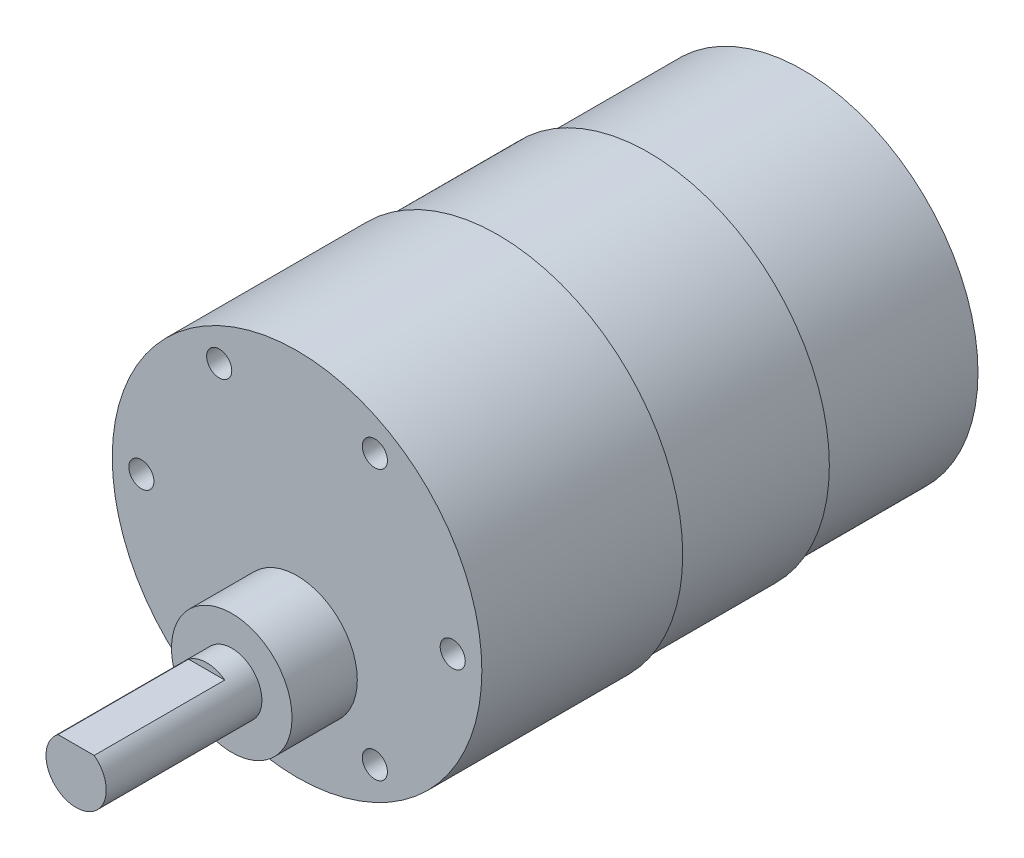
from build123d import *

# Parameters (mm, degrees)
SKETCH1_R                       = 17.4
BOSS_EXTRUDE1_DEPTH             = 15.4
SKETCH2_R                       = 18
BOSS_EXTRUDE2_DEPTH             = 15
SKETCH3_R                       = 18.4
BOSS_EXTRUDE3_DEPTH             = 20
SKETCH4_R                       = 6
BOSS_EXTRUDE4_DEPTH             = 6.5
SKETCH5_R                       = 3
BOSS_EXTRUDE5_DEPTH             = 15.5
CUT_EXTRUDE1_DEPTH              = 13
TAP_DRILL_FOR_M3X0_5_TAP1_D     = 2.5
TAP_DRILL_FOR_M3X0_5_TAP1_DEPTH = 10.76


with BuildPart() as part:
    # Sketch1 → Boss-Extrude1 (new body)
    with BuildSketch(Plane.XY):
        Circle(SKETCH1_R)
    extrude(amount=BOSS_EXTRUDE1_DEPTH)

    # Sketch2 → Boss-Extrude2 (add)
    with BuildSketch(Plane.XY.offset(15.4)):
        Circle(SKETCH2_R)
    extrude(amount=BOSS_EXTRUDE2_DEPTH)

    # Sketch3 → Boss-Extrude3 (add)
    with BuildSketch(Plane.XY.offset(30.4)):
        Circle(SKETCH3_R)
    extrude(amount=BOSS_EXTRUDE3_DEPTH)

    # Sketch4 → Boss-Extrude4 (add)
    with BuildSketch(Plane.XY.offset(50.4)):
        with Locations((0, -7)):
            Circle(SKETCH4_R)
    extrude(amount=BOSS_EXTRUDE4_DEPTH)

    # Sketch5 → Boss-Extrude5 (add)
    with BuildSketch(Plane.XY.offset(56.9)):
        with Locations((0, -7)):
            Circle(SKETCH5_R)
    extrude(amount=BOSS_EXTRUDE5_DEPTH)

    # Sketch6 → Cut-Extrude1 (cut)
    with BuildSketch(Plane.XY.offset(72.4)):
        with BuildLine():
            Line((-1.8, -4.6), (1.8, -4.6))
            ThreePointArc((1.8, -4.6), (0, -4), (-1.8, -4.6))
        make_face()
    extrude(amount=-CUT_EXTRUDE1_DEPTH, mode=Mode.SUBTRACT)

    # Tap Drill for M3x0.5 Tap1
    with Locations(Plane.XY.offset(50.4)):
        with Locations((-15.5, 0), (-7.75, 13.423393759), (7.75, 13.423393759), (15.5, 0), (7.75, -13.423393759), (-7.75, -13.423393759)):
            Hole(TAP_DRILL_FOR_M3X0_5_TAP1_D / 2, depth=TAP_DRILL_FOR_M3X0_5_TAP1_DEPTH)


solid = part.part
